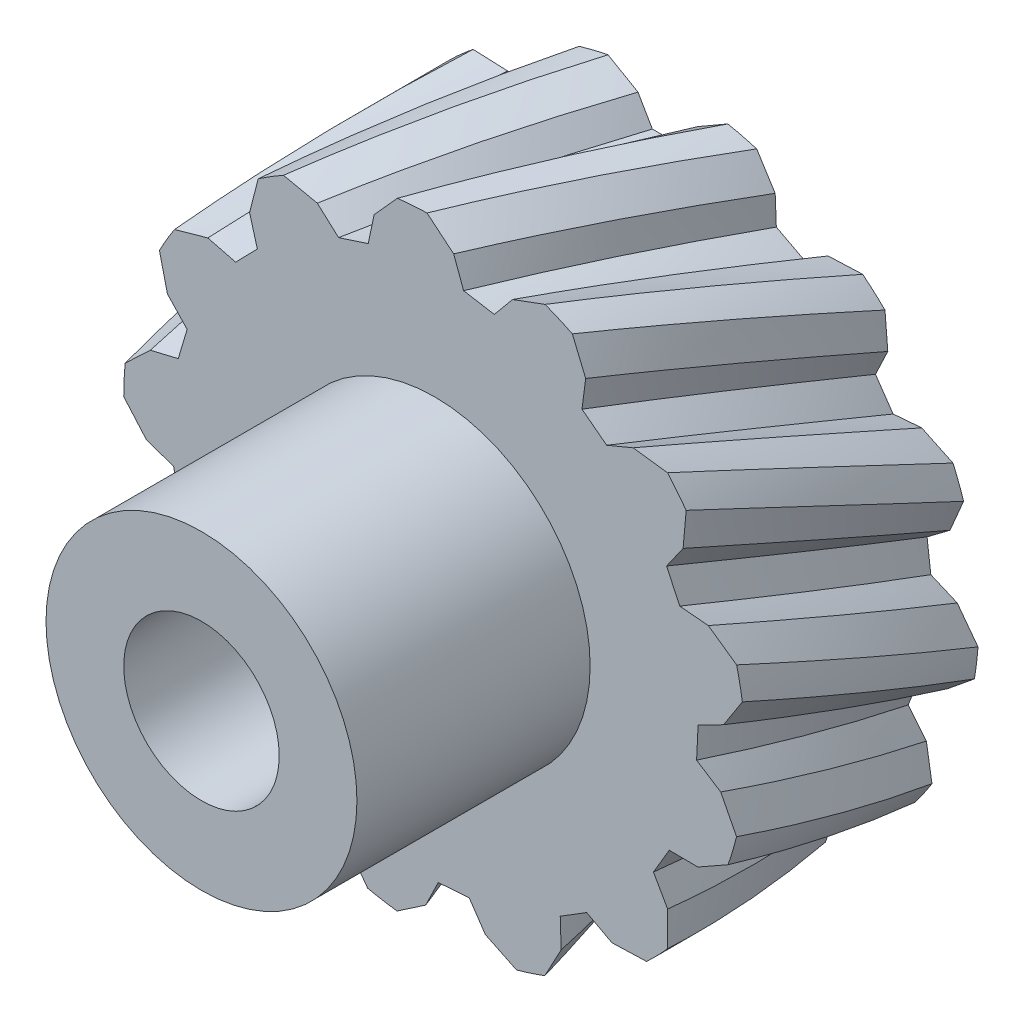
from build123d import *

# Parameters (mm, degrees)
IZIM1_R                     = 20
Y_KSEKLIK_EKSTR_ZYON1_DEPTH = 30
IZIM2_R                     = 20
IZIM2_R_2                   = 10
KES_EKSTR_ZYON2_DEPTH       = 15
IZIM3_R                     = 5
KES_EKSTR_ZYON3_DEPTH       = 40
KES_S_P_R2_PITCH            = 300
KES_S_P_R2_HEIGHT           = 15
KES_S_P_R2_RADIUS           = 20
KES_S_P_R2_START_ANGLE      = 90
DAIRESEL_KAPLAMA1_COUNT     = 13


with BuildPart() as part:
    # Çizim1 → Yükseklik-Ekstrüzyon1 (new body)
    with BuildSketch(Plane.XY):
        Circle(IZIM1_R)
    extrude(amount=Y_KSEKLIK_EKSTR_ZYON1_DEPTH)

    # Çizim2 → Kes-Ekstrüzyon2 (cut)
    with BuildSketch(Plane.XY.offset(30)):
        Circle(IZIM2_R)
        Circle(IZIM2_R_2, mode=Mode.SUBTRACT)
    extrude(amount=-KES_EKSTR_ZYON2_DEPTH, mode=Mode.SUBTRACT)

    # Çizim3 → Kes-Ekstrüzyon3 (cut)
    with BuildSketch(Plane.XY.offset(30)):
        Circle(IZIM3_R)
    extrude(amount=-KES_EKSTR_ZYON3_DEPTH, mode=Mode.SUBTRACT)

    # Kes-Süpür2: sweep along a helix
    with BuildLine() as kes_s_p_r2_path:
        add(Helix(KES_S_P_R2_PITCH, KES_S_P_R2_HEIGHT, KES_S_P_R2_RADIUS, center=(0, 0, 0), direction=(0, 0, 1), mode=Mode.PRIVATE).rotate(Axis((0, 0, 0), (0, 0, 1)), KES_S_P_R2_START_ANGLE))
    # Çizim6 → Kes-Süpür2 (sweep, cut)
    with BuildSketch(Plane(origin=(0, 0, 0), x_dir=(-1, 0, 0), z_dir=(0, 0, -1))):
        Polygon((-1, 16.91464394), (1, 16.91464394), (1.922433482, 18.512345598), (4.766794939, 20.154538451), (-4.766794939, 20.154538451), (-1.922433482, 18.512345598), align=None)
    kes_s_p_r2 = sweep(path=kes_s_p_r2_path.line, is_frenet=True, mode=Mode.SUBTRACT)

    # Dairesel Kaplama1: Kes-Süpür2 ×13 about axis
    dairesel_kaplama1_axis = Axis((0, 0, 0), (0, 0, 1))
    for i in range(1, DAIRESEL_KAPLAMA1_COUNT):
        add(kes_s_p_r2.rotate(dairesel_kaplama1_axis, i * 360 / DAIRESEL_KAPLAMA1_COUNT), mode=Mode.SUBTRACT)


solid = part.part
